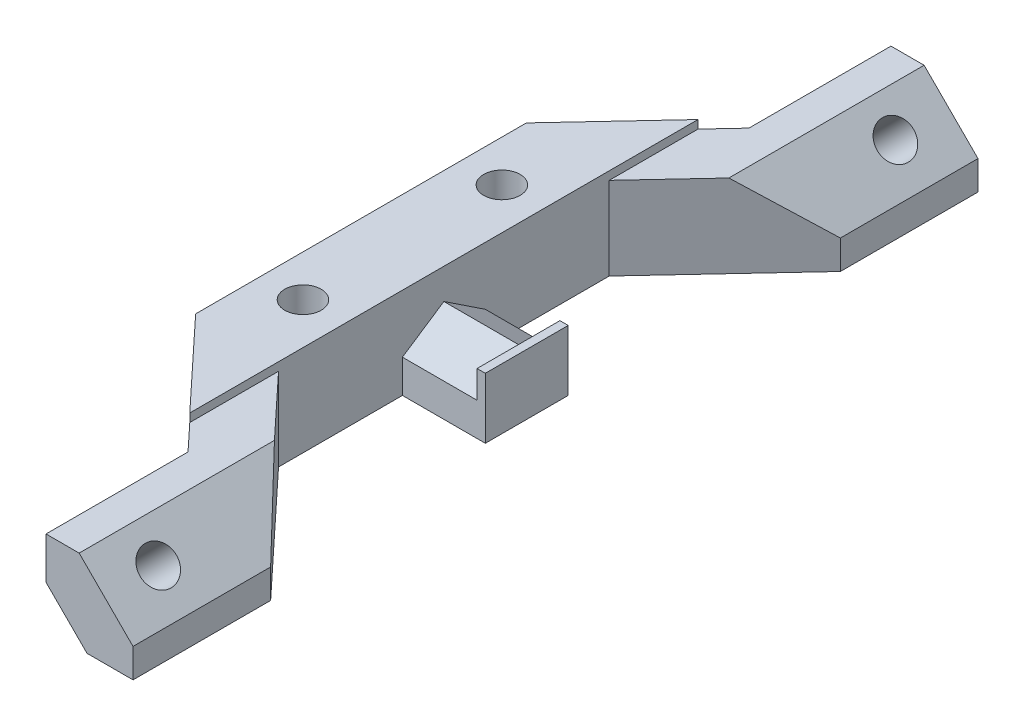
from build123d import *

# Parameters (mm, degrees)
BOSS_EXTRUDE1_DEPTH = 10
CUT_EXTRUDE1_DEPTH  = 102.942524855
SKETCH15_R          = 2.2
CUT_EXTRUDE5_DEPTH  = 20.069609228
CUT_EXTRUDE6_DEPTH  = 15
CUT_EXTRUDE7_DEPTH  = 15
BOSS_EXTRUDE2_DEPTH = 9
SKETCH21_W          = 10
SKETCH21_H          = 7.31662479
BOSS_EXTRUDE3_DEPTH = 1
SKETCH17_R          = 2.2
CUT_EXTRUDE8_DEPTH  = 11
SKETCH22_R          = 3.5
CUT_EXTRUDE9_DEPTH  = 4
SKETCH23_R          = 2.2
BOSS_EXTRUDE4_DEPTH = 1


with BuildPart() as part:
    # Sketch1 → Boss-Extrude1 (new body)
    with BuildSketch(Plane(origin=(0, 0, 0), x_dir=(1, 0, 0), z_dir=(0, 1, 0))):
        Polygon((-5, 19.95), (7.9685, 33.8358924), (7.9685, 50.971262428), (18.4685, 50.971262428), (18.4685, 34.371262428), (5, 19.95), (5, -19.95), (18.4685, -34.371262428), (18.4685, -50.971262428), (7.9685, -50.971262428), (7.9685, -33.8358924), (-5, -19.95), align=None)
    extrude(amount=BOSS_EXTRUDE1_DEPTH)

    # Sketch2 → Cut-Extrude1 (cut, through all)
    with BuildSketch(Plane.XY.offset(50.971262428)):
        Polygon((11.9685, 10), (18.4685, 3.5), (18.4685, 10), align=None)
    extrude(amount=-CUT_EXTRUDE1_DEPTH, mode=Mode.SUBTRACT)

    # Sketch15 → Cut-Extrude5 (cut, through all)
    with BuildSketch(Plane(origin=(10.98425, 10.98425, 0), x_dir=(0, 0, -1), z_dir=(0.707106781, 0.707106781, 0))):
        with Locations(Location((44.471262428, -5.685327854, 0), (0, 0, 90))):  # turned: the seam where the file's is
            Circle(SKETCH15_R)
        with Locations(Location((-44.471262428, -5.685327854, 0), (0, 0, 178.678239242))):  # turned: the seam where the file's is
            Circle(SKETCH15_R)
    extrude(amount=-CUT_EXTRUDE5_DEPTH, mode=Mode.SUBTRACT)

    # Sketch4 → Cut-Extrude6 (cut)
    with BuildSketch(Plane.XY.offset(50.971262428)):
        Polygon((7.9685, 4.949747468), (7.9685, 0), (12.918247468, 0), align=None)
    extrude(amount=-CUT_EXTRUDE6_DEPTH, mode=Mode.SUBTRACT)

    # Sketch18 → Cut-Extrude7 (cut)
    with BuildSketch(Plane(origin=(0, 0, -50.971262428), x_dir=(-1, 0, 0), z_dir=(0, 0, -1))):
        Polygon((-7.9685, 5), (-7.9685, 0), (-12.918247468, 0), align=None)
    extrude(amount=-CUT_EXTRUDE7_DEPTH, mode=Mode.SUBTRACT)

    # Sketch13 → Boss-Extrude2 (add)
    with BuildSketch(Plane(origin=(5, 0, 0), x_dir=(0, 0, -1), z_dir=(1, 0, 0))):
        Polygon((0, 7.31662479), (-5, 4), (-5, 0), (5, 0), (5, 4), align=None)
    extrude(amount=BOSS_EXTRUDE2_DEPTH)

    # Sketch21 → Boss-Extrude3 (add)
    with BuildSketch(Plane(origin=(14, 0, 0), x_dir=(0, 0, -1), z_dir=(1, 0, 0))):
        with Locations((0, 3.658312395)):
            Rectangle(SKETCH21_W, SKETCH21_H)
    extrude(amount=BOSS_EXTRUDE3_DEPTH)

    # Sketch17 → Cut-Extrude8 (cut, through all)
    with BuildSketch(Plane(origin=(0, 10, 0), x_dir=(1, 0, 0), z_dir=(0, 1, 0))):
        with Locations(Location((0, 12, 0), (0, 0, 270))):  # turned: the seam where the file's is
            Circle(SKETCH17_R)
        with Locations(Location((0, -12, 0), (0, 0, 270))):  # turned: the seam where the file's is
            Circle(SKETCH17_R)
    extrude(amount=-CUT_EXTRUDE8_DEPTH, mode=Mode.SUBTRACT)

    # Sketch22 → Cut-Extrude9 (cut)
    with BuildSketch(Plane.XZ):
        with Locations(Location((0, 12, 0), (0, 0, 270))):  # turned: the seam where the file's is
            Circle(SKETCH22_R)
        with Locations(Location((0, -12, 0), (0, 0, 270))):  # turned: the seam where the file's is
            Circle(SKETCH22_R)
    extrude(amount=-CUT_EXTRUDE9_DEPTH, mode=Mode.SUBTRACT)

    # Sketch23 → Boss-Extrude4 (add)
    with BuildSketch(Plane(origin=(0, 10, 0), x_dir=(1, 0, 0), z_dir=(0, 1, 0))):
        Polygon((5, -30.657400548), (5, 30.657400548), (-5, 19.95), (-5, -19.95), align=None)
        with Locations(Location((0, -12, 0), (0, 0, 270))):  # turned: the seam where the file's is
            Circle(SKETCH23_R, mode=Mode.SUBTRACT)
        with Locations(Location((0, 12, 0), (0, 0, 270))):  # turned: the seam where the file's is
            Circle(SKETCH23_R, mode=Mode.SUBTRACT)
    extrude(amount=BOSS_EXTRUDE4_DEPTH)


solid = part.part
